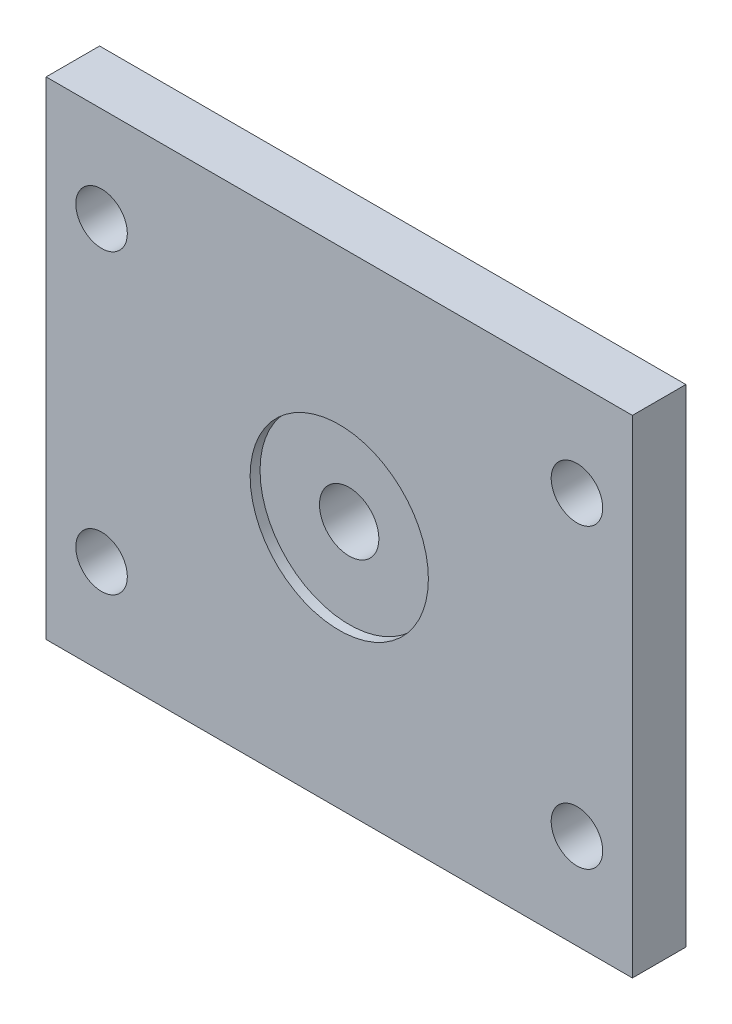
from build123d import *

# Parameters (mm, degrees)
SKETCH1_W      = 296
SKETCH1_H      = 246
SKETCH1_R      = 13
SKETCH1_R_2    = 15
EXTRUDE1_DEPTH = 27
SKETCH2_R      = 45
EXTRUDE2_DEPTH = 5


with BuildPart() as part:
    # Sketch1 → Extrude1 (new body)
    with BuildSketch(Plane.XY):
        Rectangle(SKETCH1_W, SKETCH1_H)
        with Locations((-120, 75)):
            Circle(SKETCH1_R, mode=Mode.SUBTRACT)
        with Locations((120, 75)):
            Circle(SKETCH1_R, mode=Mode.SUBTRACT)
        with Locations((120, -75)):
            Circle(SKETCH1_R, mode=Mode.SUBTRACT)
        with Locations((-120, -75)):
            Circle(SKETCH1_R, mode=Mode.SUBTRACT)
        Circle(SKETCH1_R_2, mode=Mode.SUBTRACT)
    extrude(amount=EXTRUDE1_DEPTH)

    # Sketch2 → Extrude2 (cut)
    with BuildSketch(Plane.XY.offset(27)):
        Circle(SKETCH2_R)
    extrude(amount=-EXTRUDE2_DEPTH, mode=Mode.SUBTRACT)


solid = part.part
